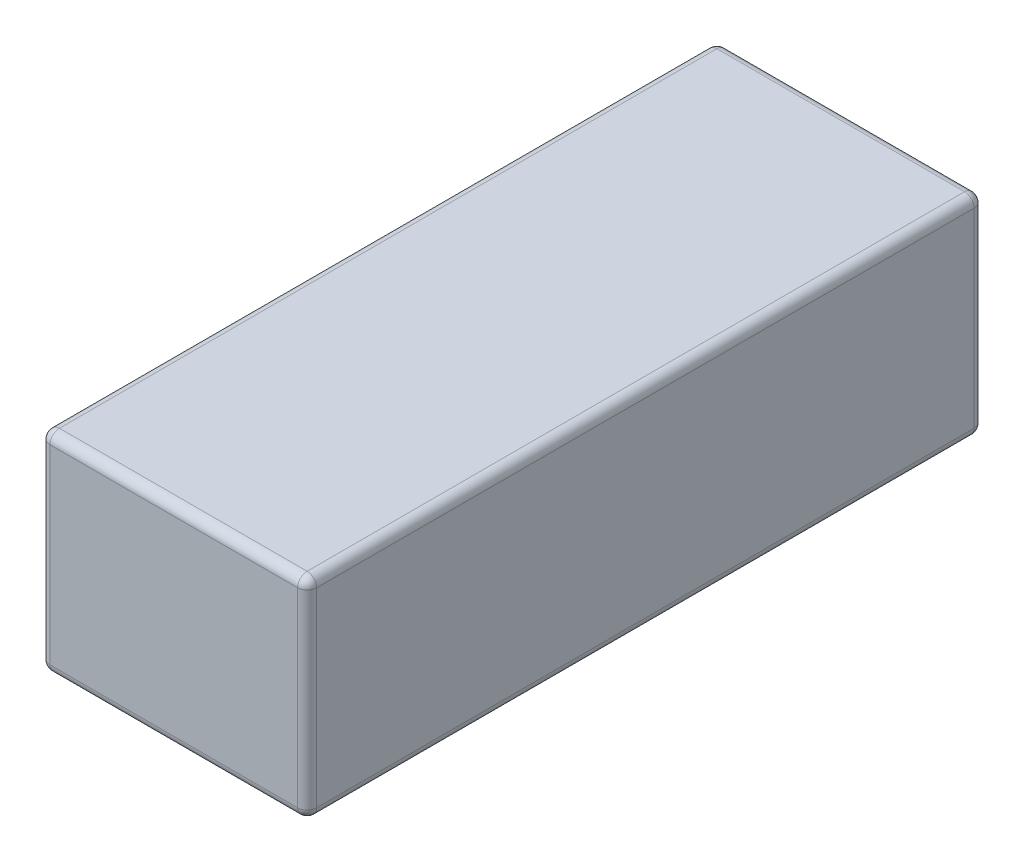
from build123d import *

# Parameters (mm, degrees)
SKETCH_1_W      = 56
SKETCH_1_H      = 44
EXTRUDE_1_DEPTH = 142
FILLET_1_R      = 2


with BuildPart() as part:
    # 草图1 → 凸台-拉伸1 (new body)
    with BuildSketch(Plane.XY):
        Rectangle(SKETCH_1_W, SKETCH_1_H)
    extrude(amount=EXTRUDE_1_DEPTH)

    # 圆角1
    fillet_1_edges = [part.edges().sort_by_distance(p)[0] for p in [
        (-28, 0, 142),
        (0, -22, 142),
        (28, 0, 142),
        (0, -22, 0),
        (-28, 0, 0),
        (0, 22, 0),
        (28, 0, 0),
        (28, -22, 71),
        (-28, -22, 71),
        (-28, 22, 71),
        (28, 22, 71),
        (0, 22, 142),
    ]]
    fillet(fillet_1_edges, radius=FILLET_1_R)


solid = part.part
